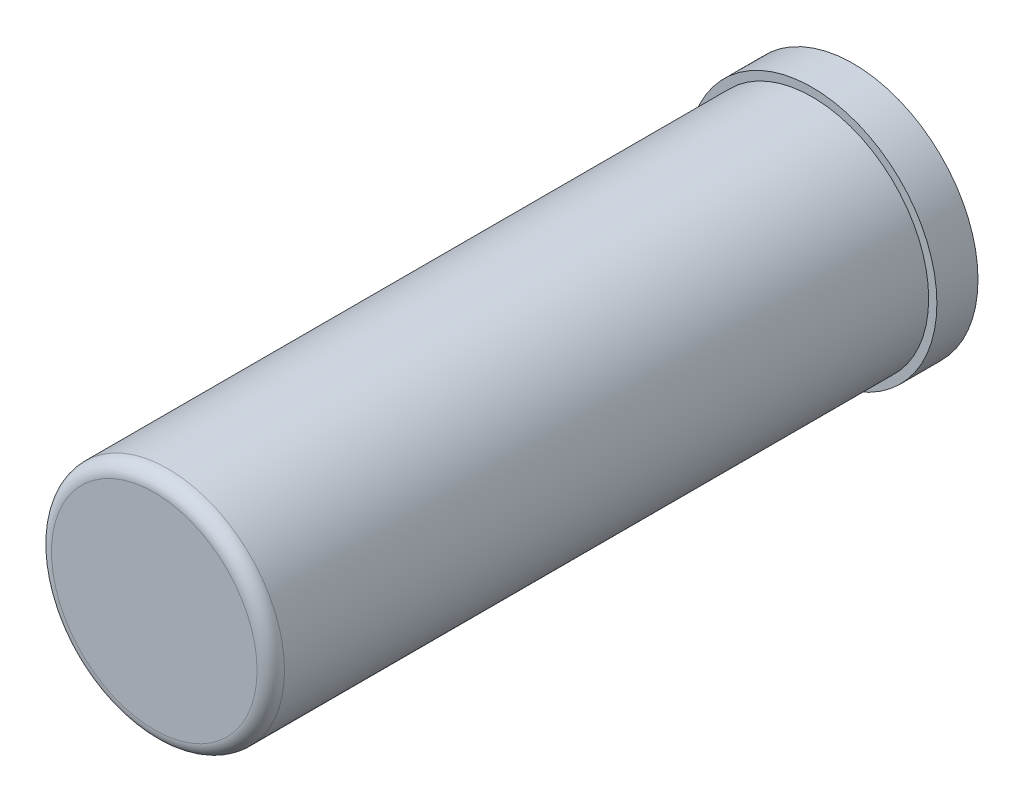
from build123d import *

# Parameters (mm, degrees)
FILLET1_R = 3.175


with BuildPart() as part:
    # Sketch1 → Revolve1 (revolve)
    with BuildSketch(Plane(origin=(0, 0, 0), x_dir=(0, 0, -1), z_dir=(1, 0, 0)), mode=Mode.PRIVATE) as revolve1_sk:
        Polygon((0, 26.9875), (0, 0), (3.175, 0), (3.175, 23.8125), (155.575, 23.8125), (155.575, 25.7175), (158.75, 25.7175), (158.75, 19.05), (152.4, 19.05), (152.4, 0), (155.575, 0), (155.575, 15.875), (161.925, 15.875), (161.925, 28.8925), (152.4, 28.8925), (152.4, 26.9875), align=None)
    revolve(revolve1_sk.sketch.rotate(Axis((0, 0, 0), (0, 0, -1)), 90), axis=Axis((0, 0, 0), (0, 0, -1)))

    # Fillet1
    fillet1_edges = [part.edges().sort_by_distance(p)[0] for p in [
        (-26.9875, 0, 0),
    ]]
    fillet(fillet1_edges, radius=FILLET1_R)


solid = part.part
